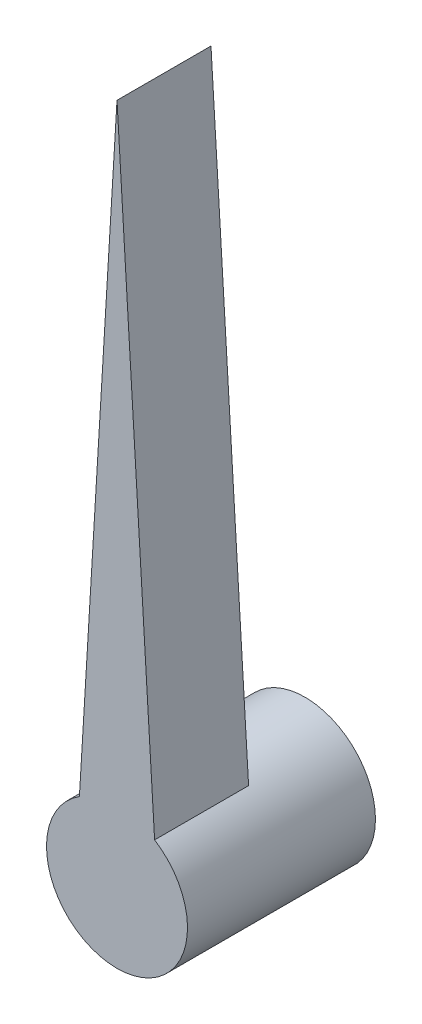
from build123d import *

# Parameters (mm, degrees)
SKETCH1_R           = 3.81
BOSS_EXTRUDE2_DEPTH = 10.16
BOSS_EXTRUDE3_DEPTH = 5.08
SKETCH5_R           = 2.413
CUT_EXTRUDE1_DEPTH  = 5.08


with BuildPart() as part:
    # Sketch1 → Boss-Extrude2 (new body)
    with BuildSketch(Plane.XY):
        Circle(SKETCH1_R)
    extrude(amount=BOSS_EXTRUDE2_DEPTH)

    # Sketch4 → Boss-Extrude3 (add)
    with BuildSketch(Plane.XY.offset(10.16)):
        Polygon((-2.032318753, 3.222697703), (2.032318753, 3.222697703), (0, 36.83), align=None)
    extrude(amount=-BOSS_EXTRUDE3_DEPTH)

    # Sketch5 → Cut-Extrude1 (cut)
    with BuildSketch(Plane(origin=(0, 0, 0), x_dir=(-1, 0, 0), z_dir=(0, 0, -1))):
        Circle(SKETCH5_R)
    extrude(amount=-CUT_EXTRUDE1_DEPTH, mode=Mode.SUBTRACT)


solid = part.part
